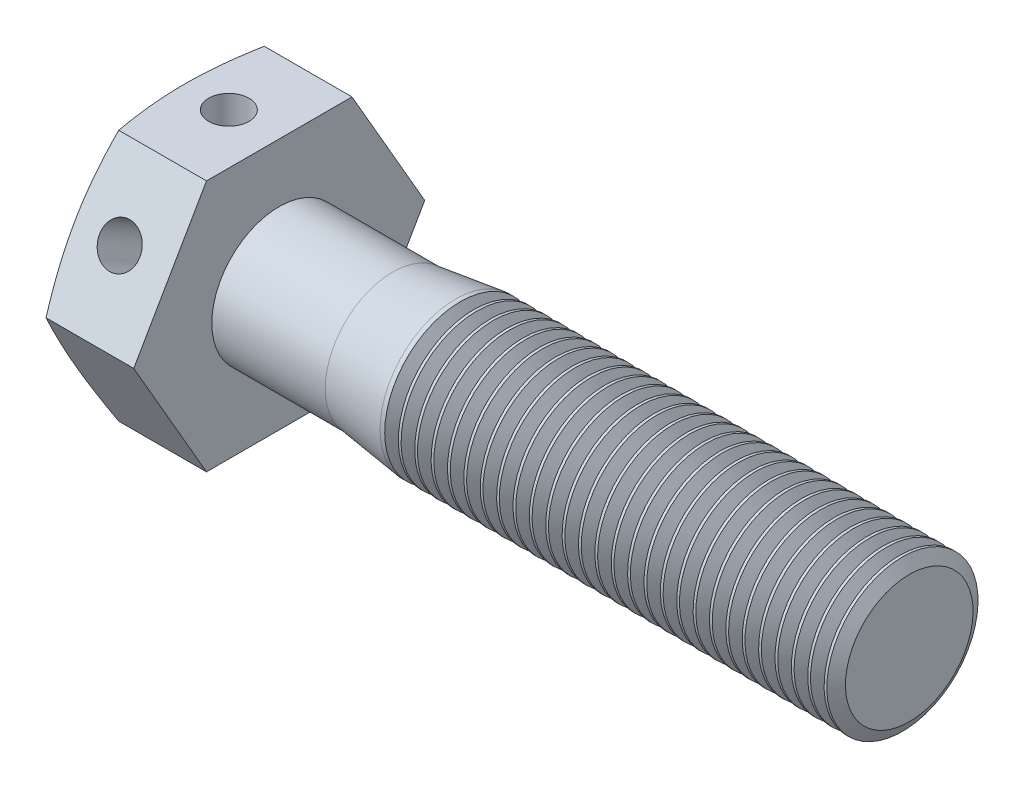
from build123d import *

# Parameters (mm, degrees)
BASEHEAD_DEPTH     = 4
SKETCH2_R          = 3
BASEBODY_DEPTH     = 25
SKETCH4_R          = 3.4
CUT_EXTRUDE1_DEPTH = 0.8
SKETCH6_R          = 0.8
HOLE_DEPTH         = 6
CIRPATTERN1_COUNT  = 2
CIRPATTERN1_ANGLE  = 60
LPATTERN10_COUNT   = 28
LPATTERN10_PITCH   = 0.6498


with BuildPart() as part:
    # Sketch1 → BaseHead (new body)
    with BuildSketch(Plane(origin=(0, 0, 0), x_dir=(0, 0, -1), z_dir=(1, 0, 0))):
        Polygon((5.773502692, 0), (2.886751346, 5), (-2.886751346, 5), (-5.773502692, 0), (-2.886751346, -5), (2.886751346, -5), align=None)
    extrude(amount=BASEHEAD_DEPTH)

    # Sketch2 → BaseBody (add)
    with BuildSketch(Plane(origin=(4, 0, 0), x_dir=(0, 0, -1), z_dir=(1, 0, 0))):
        Circle(SKETCH2_R)
    extrude(amount=BASEBODY_DEPTH)

    # Sketch3 → HeadChamfer (revolve, cut)
    with BuildSketch(Plane(origin=(3.161211974, 0, 2.612290718), x_dir=(0, 0, -1), z_dir=(0, 1, 0))):
        Polygon((8.38579341, 3.161211974), (8.38579341, 2.643099366), (6.962290718, 3.161211974), align=None)
    revolve(axis=Axis((-2.071354488, 0, 0), (1, 0, 0)), mode=Mode.SUBTRACT)

    # Sketch4 → Cut-Extrude1 (cut)
    with BuildSketch(Plane.ZY):
        Circle(SKETCH4_R)
    extrude(amount=-CUT_EXTRUDE1_DEPTH, mode=Mode.SUBTRACT)

    # Sketch5 → Cut-Revolve1 (revolve, cut)
    with BuildSketch(Plane(origin=(-2.92963122, 0, 7.92963122), x_dir=(0, 0, -1), z_dir=(0, 1, 0))):
        Polygon((10.92963122, -13.92963122), (10.60463122, -11.42963122), (10.60463122, -6.92963122), (13.27963122, -6.92963122), (13.27963122, -13.92963122), align=None)
    revolve(axis=Axis((-2.697175707, 0, 0), (1, 0, 0)), mode=Mode.SUBTRACT)

    # Sketch6 → Hole (cut, symmetric)
    with BuildSketch(Plane(origin=(0, 0, 0), x_dir=(1, 0, 0), z_dir=(0, 1, 0))):
        with Locations((2, 0)):
            Circle(SKETCH6_R)
    hole = extrude(amount=HOLE_DEPTH, both=True, mode=Mode.SUBTRACT)

    # CirPattern1: Hole ×2 about axis
    cirpattern1_axis = Axis((-2.697175707, 0, 0), (1, 0, 0))
    for i in range(1, CIRPATTERN1_COUNT):
        add(hole.rotate(cirpattern1_axis, i * CIRPATTERN1_ANGLE / (CIRPATTERN1_COUNT - 1)), mode=Mode.SUBTRACT)

    # Sketch7 → Cut-Revolve10 (revolve, cut)
    with BuildSketch(Plane.XY):
        Polygon((28.72925, 3.2), (29.27075, 3.2), (29.27075, 3), (29, 2.531047244), (28.72925, 3), align=None)
    cut_revolve10 = revolve(axis=Axis((28.86346516, 0, 0), (-1, 0, 0)), mode=Mode.SUBTRACT)

    # LPattern10: Cut-Revolve10 ×28
    with Locations(*[(-i * LPATTERN10_PITCH, 0, 0) for i in range(1, LPATTERN10_COUNT)]):
        add(cut_revolve10, mode=Mode.SUBTRACT)


solid = part.part
